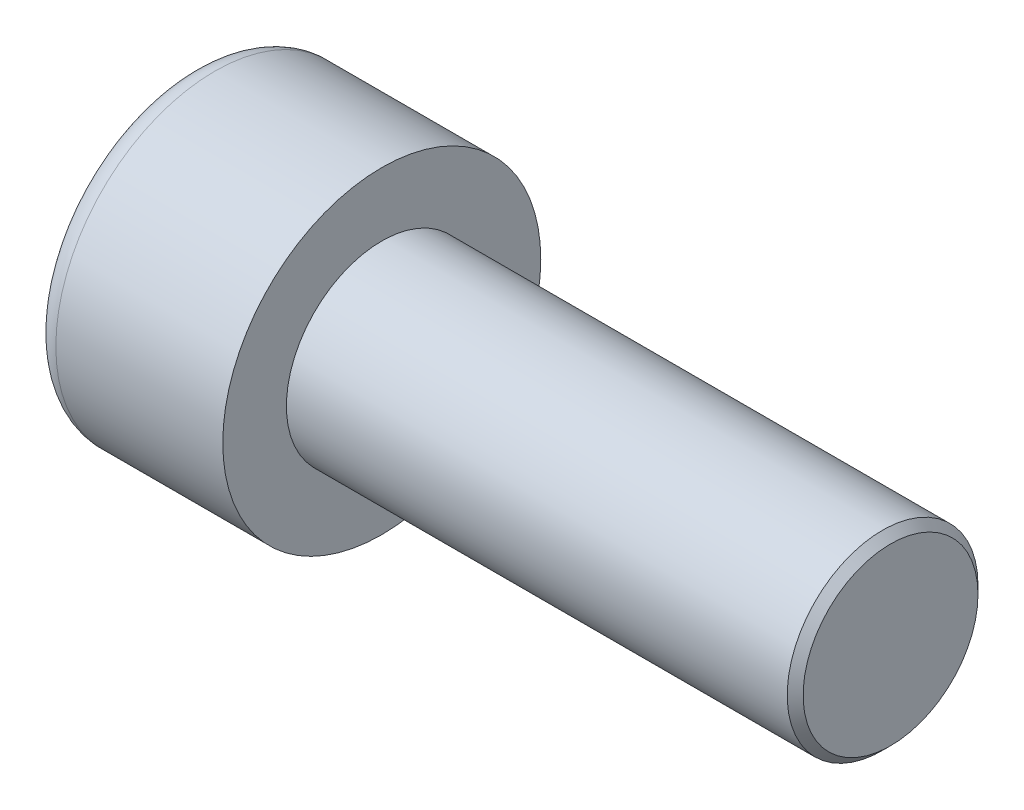
from build123d import *

# Parameters (mm, degrees)
SKETCH1_R           = 5
BASEHEAD_DEPTH      = 6
SKETCH2_R           = 3
BASEBODY_DEPTH      = 16
HEXAGONSOCKET_DEPTH = 3
TOPFILLET_R         = 0.75
CHAMFER1_SIZE       = 0.25


with BuildPart() as part:
    # Sketch1 → BaseHead (new body)
    with BuildSketch(Plane(origin=(0, 0, 0), x_dir=(0, 0, -1), z_dir=(1, 0, 0))):
        Circle(SKETCH1_R)
    extrude(amount=BASEHEAD_DEPTH)

    # Sketch2 → BaseBody (add)
    with BuildSketch(Plane(origin=(6, 0, 0), x_dir=(0, 0, -1), z_dir=(1, 0, 0))):
        Circle(SKETCH2_R)
    extrude(amount=BASEBODY_DEPTH)

    # Sketch3 → HexagonSocket (cut)
    with BuildSketch(Plane(origin=(0, 0, 0), x_dir=(0, 0, -1), z_dir=(1, 0, 0))):
        Polygon((2.886751346, 0), (1.443375673, 2.5), (-1.443375673, 2.5), (-2.886751346, 0), (-1.443375673, -2.5), (1.443375673, -2.5), align=None)
    extrude(amount=HEXAGONSOCKET_DEPTH, mode=Mode.SUBTRACT)

    # Sketch4 → Cut-Revolve1 (revolve, cut)
    with BuildSketch(Plane(origin=(-4.19613823, 0.75, 0), x_dir=(-1, 0, 0), z_dir=(0, 0, 1))):
        Polygon((-7.19613823, 3.25), (-8.639513903, 0.75), (-7.19613823, 0.75), align=None)
    revolve(axis=Axis((0.838992387, 0, 0), (-1, 0, 0)), mode=Mode.SUBTRACT)

    # TopFillet
    topfillet_edges = [part.edges().sort_by_distance(p)[0] for p in [
        (0, 0, 5),
    ]]
    fillet(topfillet_edges, radius=TOPFILLET_R)

    # Chamfer1
    chamfer1_edges = [part.edges().sort_by_distance(p)[0] for p in [
        (22, 0, 3),
    ]]
    chamfer(chamfer1_edges, length=CHAMFER1_SIZE)


solid = part.part
